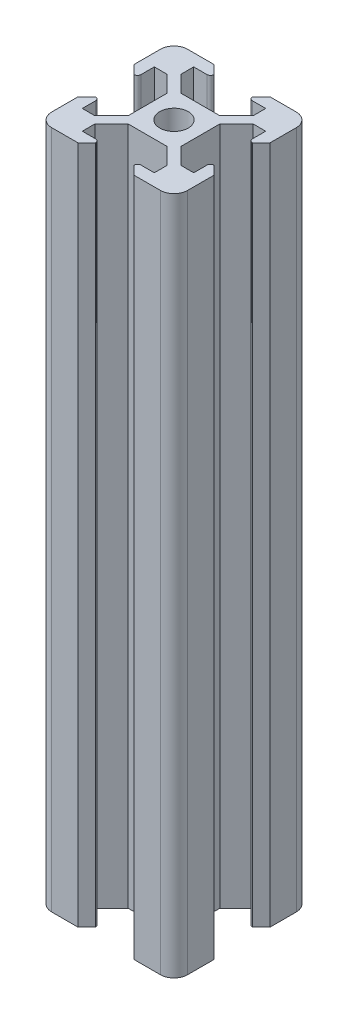
from build123d import *

# Parameters (mm, degrees)
CROQUIS1_R              = 2.1
SALIENTE_EXTRUIR2_DEPTH = 100


with BuildPart() as part:
    # Croquis1 → Saliente-Extruir2 (new body)
    with BuildSketch(Plane(origin=(0, 0, 0), x_dir=(1, 0, 0), z_dir=(0, 1, 0))):
        with BuildLine():
            Line((3.9, -2.84), (3.9, 2.84))
            Line((3.9, 2.84), (6.36, 5.3))
            Line((6.36, 5.3), (8.2, 5.3))
            Line((8.2, 5.3), (8.2, 3.34))
            ThreePointArc((8.2, 3.34), (8.346446609, 2.986446609), (8.7, 2.84))
            Line((8.7, 2.84), (10, 4.14))
            Line((10, 4.14), (10, 8))
            ThreePointArc((10, 8), (9.414213562, 9.414213562), (8, 10))
            Line((8, 10), (4.14, 10))
            Line((4.14, 10), (2.84, 8.7))
            ThreePointArc((2.84, 8.7), (2.986446609, 8.346446609), (3.34, 8.2))
            Line((3.34, 8.2), (5.3, 8.2))
            Line((5.3, 8.2), (5.3, 6.36))
            Line((5.3, 6.36), (2.84, 3.9))
            Line((2.84, 3.9), (-2.84, 3.9))
            Line((-2.84, 3.9), (-5.3, 6.36))
            Line((-5.3, 6.36), (-5.3, 8.2))
            Line((-5.3, 8.2), (-3.34, 8.2))
            ThreePointArc((-3.34, 8.2), (-2.986446609, 8.346446609), (-2.84, 8.7))
            Line((-2.84, 8.7), (-4.14, 10))
            Line((-4.14, 10), (-8, 10))
            ThreePointArc((-8, 10), (-9.414213562, 9.414213562), (-10, 8))
            Line((-10, 8), (-10, 4.14))
            Line((-10, 4.14), (-8.7, 2.84))
            ThreePointArc((-8.7, 2.84), (-8.346446609, 2.986446609), (-8.2, 3.34))
            Line((-8.2, 3.34), (-8.2, 5.3))
            Line((-8.2, 5.3), (-6.36, 5.3))
            Line((-6.36, 5.3), (-3.9, 2.84))
            Line((-3.9, 2.84), (-3.9, -2.84))
            Line((-3.9, -2.84), (-6.36, -5.3))
            Line((-6.36, -5.3), (-8.2, -5.3))
            Line((-8.2, -5.3), (-8.2, -3.34))
            ThreePointArc((-8.2, -3.34), (-8.346446609, -2.986446609), (-8.7, -2.84))
            Line((-8.7, -2.84), (-10, -4.14))
            Line((-10, -4.14), (-10, -8))
            ThreePointArc((-10, -8), (-9.414213562, -9.414213562), (-8, -10))
            Line((-8, -10), (-4.14, -10))
            Line((-4.14, -10), (-2.84, -8.7))
            ThreePointArc((-2.84, -8.7), (-2.986446609, -8.346446609), (-3.34, -8.2))
            Line((-3.34, -8.2), (-5.3, -8.2))
            Line((-5.3, -8.2), (-5.3, -6.36))
            Line((-5.3, -6.36), (-2.84, -3.9))
            Line((-2.84, -3.9), (2.84, -3.9))
            Line((2.84, -3.9), (5.3, -6.36))
            Line((5.3, -6.36), (5.3, -8.2))
            Line((5.3, -8.2), (3.34, -8.2))
            ThreePointArc((3.34, -8.2), (2.986446609, -8.346446609), (2.84, -8.7))
            Line((2.84, -8.7), (4.14, -10))
            Line((4.14, -10), (8, -10))
            ThreePointArc((8, -10), (9.414213562, -9.414213562), (10, -8))
            Line((10, -8), (10, -4.14))
            Line((10, -4.14), (8.7, -2.84))
            ThreePointArc((8.7, -2.84), (8.346446609, -2.986446609), (8.2, -3.34))
            Line((8.2, -3.34), (8.2, -5.3))
            Line((8.2, -5.3), (6.36, -5.3))
            Line((6.36, -5.3), (3.9, -2.84))
        make_face()
        Circle(CROQUIS1_R, mode=Mode.SUBTRACT)
    extrude(amount=SALIENTE_EXTRUIR2_DEPTH)


solid = part.part
